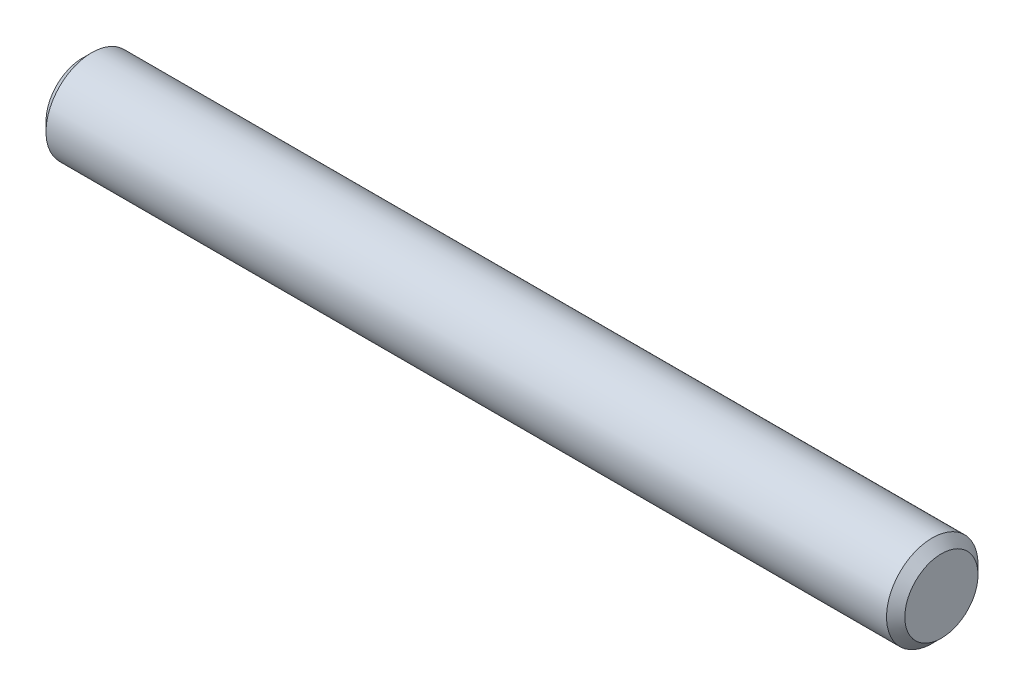
from build123d import *

# Parameters (mm, degrees)
SKETCH2_R           = 0.5953125
EXTRUDE1_DEPTH      = 5.588
EXTRUDE1_DEPTH_BACK = 5.588
CHAMFER1_SIZE       = 0.1190625


with BuildPart() as part:
    # Sketch2 → Extrude1 (new body, two sides)
    with BuildSketch(Plane(origin=(0, 0, 0), x_dir=(0, 0, -1), z_dir=(1, 0, 0))) as extrude1_sk:
        Circle(SKETCH2_R)
    extrude(amount=EXTRUDE1_DEPTH)
    extrude(extrude1_sk.sketch, amount=-EXTRUDE1_DEPTH_BACK)

    # Chamfer1
    chamfer1_edges = [part.edges().sort_by_distance(p)[0] for p in [
        (-5.588, 0, 0.5953125),
        (5.588, 0, 0.5953125),
    ]]
    chamfer(chamfer1_edges, length=CHAMFER1_SIZE)


solid = part.part
